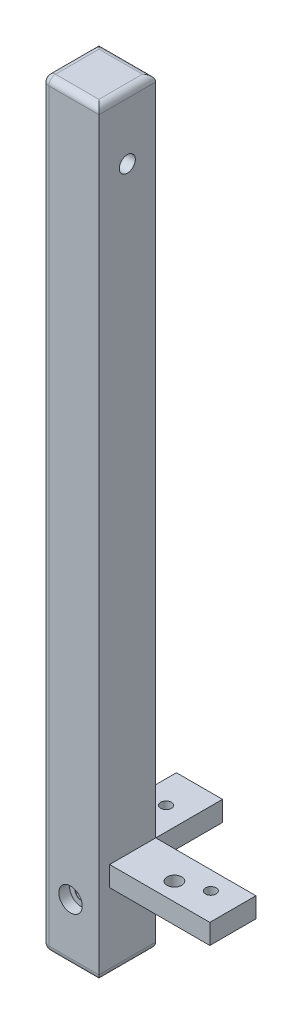
from build123d import *

# Parameters (mm, degrees)
SKETCH1_W                      = 8.5
SKETCH1_H                      = 113.5
BOSS_EXTRUDE1_DEPTH            = 8.5
SKETCH12_W                     = 8.5
SKETCH12_H                     = 3
BOSS_EXTRUDE2_DEPTH            = 15
M2X0_4_TAPPED_HOLE1_D          = 1.6
M2X0_4_TAPPED_HOLE1_DEPTH      = 5.2
M2X0_4_TAPPED_HOLE1_TIP        = 0.480688495
F_2_2_2_2_DIAMETER_HOLE1_D     = 2.2
F_2_2_2_2_DIAMETER_HOLE1_DEPTH = 13
SKETCH25_W                     = 8.5
SKETCH25_H                     = 3
BOSS_EXTRUDE3_DEPTH            = 10
SKETCH30_W                     = 5.5
SKETCH30_H                     = 8.5
CUT_EXTRUDE2_DEPTH             = 5
SKETCH31_R                     = 1
CUT_EXTRUDE3_DEPTH             = 2
FILLET1_R                      = 1
M2X0_4_TAPPED_HOLE3_D          = 1.6
M2X0_4_TAPPED_HOLE3_DEPTH      = 3
M2X0_4_TAPPED_HOLE2_D          = 2
M2X0_4_TAPPED_HOLE2_DEPTH      = 5.2
M2X0_4_TAPPED_HOLE2_TIP        = 0.600860619
SKETCH45_W                     = 1.6
SKETCH45_H                     = 10
SKETCH45_W_2                   = 15
SKETCH45_H_2                   = 1.6
CUT_EXTRUDE4_DEPTH             = 10


with BuildPart() as part:
    # Sketch1 → Boss-Extrude1 (new body)
    with BuildSketch(Plane.XY):
        with Locations((4.25, -56.75)):
            Rectangle(SKETCH1_W, SKETCH1_H)
    extrude(amount=BOSS_EXTRUDE1_DEPTH)

    # Sketch12 → Boss-Extrude2 (add)
    with BuildSketch(Plane(origin=(8.5, 0, 0), x_dir=(0, 0, -1), z_dir=(1, 0, 0))):
        with Locations((-4.25, -100.5)):
            Rectangle(SKETCH12_W, SKETCH12_H)
    extrude(amount=BOSS_EXTRUDE2_DEPTH)

    # M2x0.4 Tapped Hole1
    with Locations(Plane(origin=(0, -99, 0), x_dir=(1, 0, 0), z_dir=(0, 1, 0))):
        with Locations((19.5, -2.75)):
            Hole(M2X0_4_TAPPED_HOLE1_D / 2, depth=M2X0_4_TAPPED_HOLE1_DEPTH)
            with Locations((0, 0, -(M2X0_4_TAPPED_HOLE1_DEPTH + M2X0_4_TAPPED_HOLE1_TIP / 2))):  # 118° drill point
                Cone(0, M2X0_4_TAPPED_HOLE1_D / 2, M2X0_4_TAPPED_HOLE1_TIP, mode=Mode.SUBTRACT)

    # Ø2.2 (2.2) Diameter Hole1
    with Locations(Plane(origin=(0, -99, 0), x_dir=(1, 0, 0), z_dir=(0, 1, 0))):
        with Locations((15.5, -4.2)):
            Hole(F_2_2_2_2_DIAMETER_HOLE1_D / 2, depth=F_2_2_2_2_DIAMETER_HOLE1_DEPTH)

    # Sketch19 → CBORE for M2 Socket Head Cap Screw1 (revolve, cut)
    with BuildSketch(Plane(origin=(0, -9.5, 4.25), x_dir=(0, 0, 1), z_dir=(0, 1, 0))):
        Polygon((0, 0), (0, 23.500025), (1.2, 23.500025), (1.2, 2.025), (1.225, 2), (2.2, 2), (2.2, 0), align=None)
    revolve(axis=Axis((-6.35, -9.5, 4.25), (1, 0, 0)), mode=Mode.SUBTRACT)

    # Sketch25 → Boss-Extrude3 (add)
    with BuildSketch(Plane(origin=(0, 0, 0), x_dir=(-1, 0, 0), z_dir=(0, 0, -1))):
        with Locations((-4.25, -100.5)):
            Rectangle(SKETCH25_W, SKETCH25_H)
    extrude(amount=BOSS_EXTRUDE3_DEPTH)

    # Sketch30 → Cut-Extrude2 (cut)
    with BuildSketch(Plane(origin=(0, 0, 0), x_dir=(-1, 0, 0), z_dir=(0, 0, -1))):
        with Locations((-4.25, -107.75)):
            Rectangle(SKETCH30_W, SKETCH30_H)
    extrude(amount=-CUT_EXTRUDE2_DEPTH, mode=Mode.SUBTRACT)

    # Sketch31 → Cut-Extrude3 (cut)
    with BuildSketch(Plane(origin=(0, -113.5, 0), x_dir=(-1, 0, 0), z_dir=(0, -1, 0))):
        with Locations((-4.25, -4.25)):
            Circle(SKETCH31_R)
    extrude(amount=-CUT_EXTRUDE3_DEPTH, mode=Mode.SUBTRACT)

    # Fillet1
    fillet1_edges = [part.edges().sort_by_distance(p)[0] for p in [
        (4.25, 0, 8.5),
        (0, -56.75, 8.5),
        (4.25, 0, 0),
        (4.25, -113.5, 0),
        (4.25, -113.5, 8.5),
        (0, 0, 4.25),
        (8.5, 0, 4.25),
        (8.5, -113.5, 4.25),
        (0, -113.5, 4.25),
        (5.25, -113.5, 4.25),
    ]]
    fillet(fillet1_edges, radius=FILLET1_R)

    # M2x0.4 Tapped Hole3
    with Locations(Plane(origin=(0, -99, 0), x_dir=(1, 0, 0), z_dir=(0, 1, 0))):
        with Locations((5.05, 5)):
            Hole(M2X0_4_TAPPED_HOLE3_D / 2, depth=M2X0_4_TAPPED_HOLE3_DEPTH)

    # M2x0.4 Tapped Hole2
    with Locations(Plane(origin=(0, 0, 0), x_dir=(-1, 0, 0), z_dir=(0, 0, -1))):
        with Locations((-5.05, -26.8), (-5.05, -84.2), (-5.05, -31.1), (-5.05, -79.9)):
            Hole(M2X0_4_TAPPED_HOLE2_D / 2, depth=M2X0_4_TAPPED_HOLE2_DEPTH)
            with Locations((0, 0, -(M2X0_4_TAPPED_HOLE2_DEPTH + M2X0_4_TAPPED_HOLE2_TIP / 2))):  # 118° drill point
                Cone(0, M2X0_4_TAPPED_HOLE2_D / 2, M2X0_4_TAPPED_HOLE2_TIP, mode=Mode.SUBTRACT)

    # Sketch43 → CBORE for M1.6 Socket Head Cap Screw1 (revolve, cut)
    with BuildSketch(Plane(origin=(4.25, -104.85, 8.5), x_dir=(0, -1, 0), z_dir=(1, 0, 0))):
        Polygon((0, 0), (0, 18.500025), (0.9, 18.500025), (0.9, 1.625), (0.925, 1.6), (1.75, 1.6), (1.75, 0), align=None)
    revolve(axis=Axis((4.25, -104.85, 14.85), (0, 0, -1)), mode=Mode.SUBTRACT)

    # Sketch45 → Cut-Extrude4 (cut)
    with BuildSketch(Plane(origin=(0, -99, 0), x_dir=(1, 0, 0), z_dir=(0, 1, 0))):
        with Locations((0.8, 5)):
            Rectangle(SKETCH45_W, SKETCH45_H)
        with Locations((16, -7.7)):
            Rectangle(SKETCH45_W_2, SKETCH45_H_2)
    extrude(amount=-CUT_EXTRUDE4_DEPTH, mode=Mode.SUBTRACT)


solid = part.part
